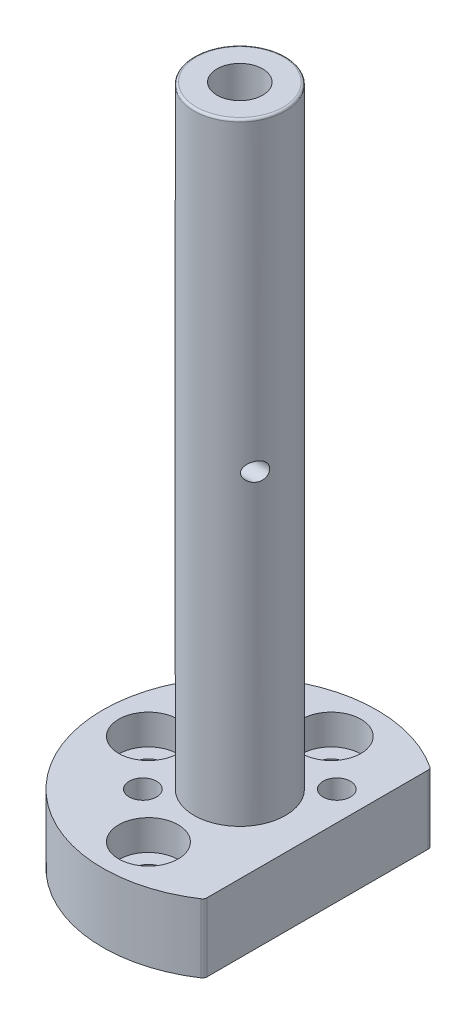
from build123d import *

# Parameters (mm, degrees)
BOSS_EXTRUDE1_DEPTH = 15
SKETCH2_R           = 10
BOSS_EXTRUDE2_DEPTH = 134
SKETCH4_R           = 7.25
CUT_EXTRUDE1_DEPTH  = 57
SKETCH5_R           = 5
CUT_EXTRUDE2_DEPTH  = 93
SKETCH7_R           = 6.5
CUT_EXTRUDE3_DEPTH  = 6.6
SKETCH8_R           = 3.3
CUT_EXTRUDE4_DEPTH  = 9.4
SKETCH9_R           = 3
CUT_EXTRUDE5_DEPTH  = 16
FILLET1_R           = 1
FILLET2_R           = 0.5
SKETCH10_R          = 2
CUT_EXTRUDE11_DEPTH = 48


with BuildPart() as part:
    # Sketch1 → Boss-Extrude1 (new body)
    with BuildSketch(Plane(origin=(0, 0, 0), x_dir=(1, 0, 0), z_dir=(0, 1, 0))):
        with BuildLine():
            Line((17, -24.718414189), (17, 24.718414189))
            ThreePointArc((17, 24.718414189), (-30, 0), (17, -24.718414189))
        make_face()
    extrude(amount=BOSS_EXTRUDE1_DEPTH)

    # Sketch2 → Boss-Extrude2 (add)
    with BuildSketch(Plane(origin=(0, 15, 0), x_dir=(1, 0, 0), z_dir=(0, 1, 0))):
        Circle(SKETCH2_R)
    extrude(amount=BOSS_EXTRUDE2_DEPTH)

    # Sketch4 → Cut-Extrude1 (cut)
    with BuildSketch(Plane.XZ):
        Circle(SKETCH4_R)
    extrude(amount=-CUT_EXTRUDE1_DEPTH, mode=Mode.SUBTRACT)

    # Sketch5 → Cut-Extrude2 (cut, through all)
    with BuildSketch(Plane.XZ.offset(-57)):
        Circle(SKETCH5_R)
    extrude(amount=-CUT_EXTRUDE2_DEPTH, mode=Mode.SUBTRACT)

    # Sketch7 → Cut-Extrude3 (cut)
    with BuildSketch(Plane(origin=(0, 15, 0), x_dir=(1, 0, 0), z_dir=(0, 1, 0))):
        with Locations((0, -20)):
            Circle(SKETCH7_R)
        with Locations((-20, 0)):
            Circle(SKETCH7_R)
        with Locations((0, 20)):
            Circle(SKETCH7_R)
    extrude(amount=-CUT_EXTRUDE3_DEPTH, mode=Mode.SUBTRACT)

    # Sketch8 → Cut-Extrude4 (cut, through all)
    with BuildSketch(Plane(origin=(0, 8.4, 0), x_dir=(1, 0, 0), z_dir=(0, 1, 0))):
        with Locations((0, -20)):
            Circle(SKETCH8_R)
        with Locations((-20, 0)):
            Circle(SKETCH8_R)
        with Locations((0, 20)):
            Circle(SKETCH8_R)
    extrude(amount=-CUT_EXTRUDE4_DEPTH, mode=Mode.SUBTRACT)

    # Sketch9 → Cut-Extrude5 (cut, through all)
    with BuildSketch(Plane(origin=(0, 15, 0), x_dir=(1, 0, 0), z_dir=(0, 1, 0))):
        with Locations((-10.606601718, -10.606601718)):
            Circle(SKETCH9_R)
        with Locations((10.606601718, 10.606601718)):
            Circle(SKETCH9_R)
    extrude(amount=-CUT_EXTRUDE5_DEPTH, mode=Mode.SUBTRACT)

    # Fillet1
    fillet1_edges = [part.edges().sort_by_distance(p)[0] for p in [
        (17, 7.5, -24.718414189),
        (17, 7.5, 24.718414189),
    ]]
    fillet(fillet1_edges, radius=FILLET1_R)

    # Fillet2
    fillet2_edges = [part.edges().sort_by_distance(p)[0] for p in [
        (-10, 149, 0),
    ]]
    fillet(fillet2_edges, radius=FILLET2_R)

    # Sketch10 → Cut-Extrude11 (cut, through all)
    with BuildSketch(Plane(origin=(17, 0, 0), x_dir=(0, 0, -1), z_dir=(1, 0, 0))):
        with Locations((-5, 82)):
            Circle(SKETCH10_R)
    extrude(amount=-CUT_EXTRUDE11_DEPTH, mode=Mode.SUBTRACT)


solid = part.part
